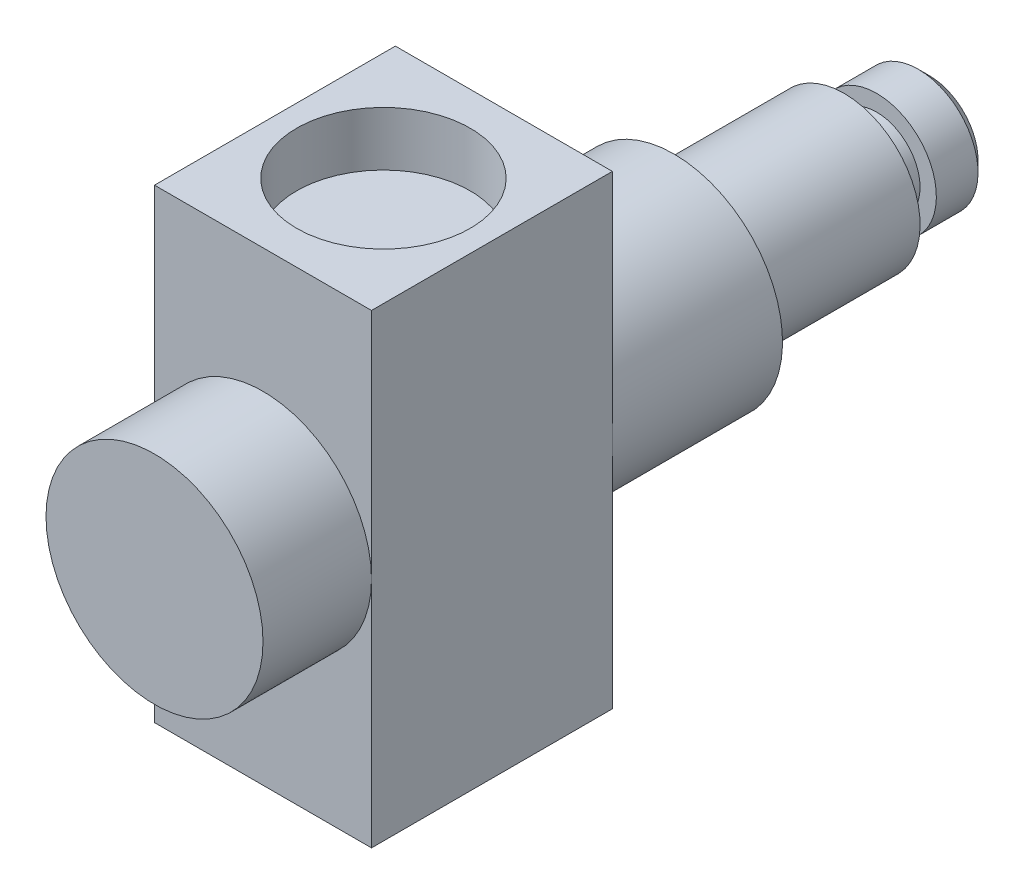
from build123d import *

# Parameters (mm, degrees)
SKETCH3_W           = 22.2
SKETCH3_H           = 42.9
BOSS_EXTRUDE2_DEPTH = 20
SKETCH4_R           = 8
CUT_EXTRUDE1_DEPTH  = 5
SKETCH5_R           = 8
CUT_EXTRUDE2_DEPTH  = 5
SKETCH11_R          = 10
BOSS_EXTRUDE3_DEPTH = 39.2
SKETCH13_R          = 10
SKETCH13_R_2        = 7
CUT_EXTRUDE5_DEPTH  = 23.52
SKETCH14_R          = 7
SKETCH14_R_2        = 5.5
CUT_EXTRUDE6_DEPTH  = 7.84
CHAMFER2_SIZE       = 1
SKETCH15_R          = 5.5
SKETCH15_R_2        = 4
CUT_EXTRUDE7_DEPTH  = 3
SKETCH16_R          = 10
BOSS_EXTRUDE4_DEPTH = 10


with BuildPart() as part:
    # Sketch3 → Boss-Extrude2 (new body)
    with BuildSketch(Plane(origin=(0, 0, 0), x_dir=(0, 0, -1), z_dir=(1, 0, 0))):
        Rectangle(SKETCH3_W, SKETCH3_H)
    extrude(amount=BOSS_EXTRUDE2_DEPTH)

    # Sketch4 → Cut-Extrude1 (cut)
    with BuildSketch(Plane(origin=(0, 21.45, 0), x_dir=(1, 0, 0), z_dir=(0, 1, 0))):
        with Locations((10, 0)):
            Circle(SKETCH4_R)
    extrude(amount=-CUT_EXTRUDE1_DEPTH, mode=Mode.SUBTRACT)

    # Sketch5 → Cut-Extrude2 (cut)
    with BuildSketch(Plane.XZ.offset(21.45)):
        with Locations((10, 0)):
            Circle(SKETCH5_R)
    extrude(amount=-CUT_EXTRUDE2_DEPTH, mode=Mode.SUBTRACT)

    # Sketch11 → Boss-Extrude3 (add)
    with BuildSketch(Plane(origin=(0, 0, -11.1), x_dir=(-1, 0, 0), z_dir=(0, 0, -1))):
        with Locations((-10, 0)):
            Circle(SKETCH11_R)
    extrude(amount=BOSS_EXTRUDE3_DEPTH)

    # Sketch13 → Cut-Extrude5 (cut)
    with BuildSketch(Plane(origin=(0, 0, -50.3), x_dir=(-1, 0, 0), z_dir=(0, 0, -1))):
        with Locations((-10, 0)):
            Circle(SKETCH13_R)
        with Locations((-10, 0)):
            Circle(SKETCH13_R_2, mode=Mode.SUBTRACT)
    extrude(amount=-CUT_EXTRUDE5_DEPTH, mode=Mode.SUBTRACT)

    # Sketch14 → Cut-Extrude6 (cut)
    with BuildSketch(Plane(origin=(0, 0, -50.3), x_dir=(-1, 0, 0), z_dir=(0, 0, -1))):
        with Locations((-10, 0)):
            Circle(SKETCH14_R)
        with Locations((-10, 0)):
            Circle(SKETCH14_R_2, mode=Mode.SUBTRACT)
    extrude(amount=-CUT_EXTRUDE6_DEPTH, mode=Mode.SUBTRACT)

    # Chamfer2
    chamfer2_edges = [part.edges().sort_by_distance(p)[0] for p in [
        (15.5, 0, -50.3),
    ]]
    chamfer(chamfer2_edges, length=CHAMFER2_SIZE)

    # Sketch15 → Cut-Extrude7 (cut)
    with BuildSketch(Plane(origin=(0, 0, -42.46), x_dir=(-1, 0, 0), z_dir=(0, 0, -1))):
        with Locations((-10, 0)):
            Circle(SKETCH15_R)
        with Locations((-10, 0)):
            Circle(SKETCH15_R_2, mode=Mode.SUBTRACT)
    extrude(amount=CUT_EXTRUDE7_DEPTH, mode=Mode.SUBTRACT)

    # Sketch16 → Boss-Extrude4 (add)
    with BuildSketch(Plane.XY.offset(11.1)):
        with Locations((10, 0)):
            Circle(SKETCH16_R)
    extrude(amount=BOSS_EXTRUDE4_DEPTH)


solid = part.part
